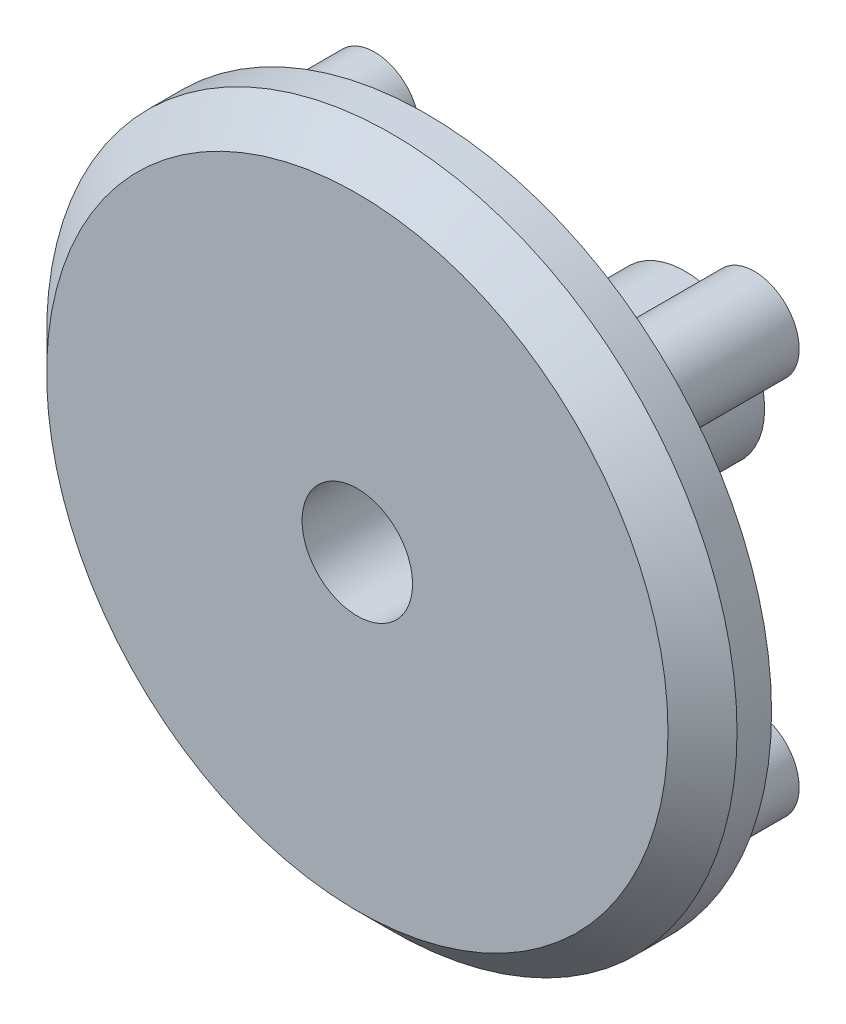
from build123d import *

# Parameters (mm, degrees)
SKETCH1_R           = 10
SKETCH1_R_2         = 1.6
BOSS_EXTRUDE1_DEPTH = 2
SKETCH1_3_R         = 1.3
BOSS_EXTRUDE2_DEPTH = 4
CHAMFER1_SIZE       = 1
BOSS_EXTRUDE4_START = -7.5
SKETCH1_5_R         = 2.3
SKETCH1_5_R_2       = 1.6
BOSS_EXTRUDE4_DEPTH = 7.5


with BuildPart() as part:
    # Sketch1 → Boss-Extrude1 (new body)
    with BuildSketch(Plane.XY):
        Circle(SKETCH1_R)
        Circle(SKETCH1_R_2, mode=Mode.SUBTRACT)
    extrude(amount=BOSS_EXTRUDE1_DEPTH)

    # Sketch1_3 → Boss-Extrude2 (add)
    with BuildSketch(Plane.XY):
        with Locations((5.5, 5.5)):
            Circle(SKETCH1_3_R)
        with Locations((5.5, -5.5)):
            Circle(SKETCH1_3_R)
        with Locations((-5.5, -5.5)):
            Circle(SKETCH1_3_R)
        with Locations((-5.5, 5.5)):
            Circle(SKETCH1_3_R)
    extrude(amount=-BOSS_EXTRUDE2_DEPTH)

    # Chamfer1
    chamfer1_edges = [part.edges().sort_by_distance(p)[0] for p in [
        (-10, 0, 2),
    ]]
    chamfer(chamfer1_edges, length=CHAMFER1_SIZE)

    # Sketch1_5 → Boss-Extrude4 (add)
    with BuildSketch(Plane.XY.offset(BOSS_EXTRUDE4_START)):
        Circle(SKETCH1_5_R)
        Circle(SKETCH1_5_R_2, mode=Mode.SUBTRACT)
    extrude(amount=BOSS_EXTRUDE4_DEPTH)


solid = part.part
